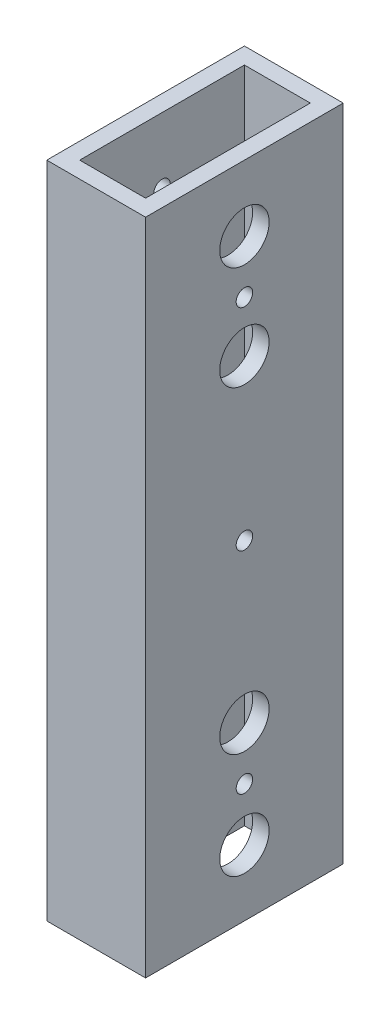
from build123d import *

# Parameters (mm, degrees)
SKETCH1_W           = 19.05
SKETCH1_H           = 38.1
SKETCH1_W_2         = 12.7
SKETCH1_H_2         = 31.75
BOSS_EXTRUDE1_DEPTH = 127
SKETCH2_R           = 1.5875
CUT_EXTRUDE1_DEPTH  = 20.05
CUT_EXTRUDE2_REACH  = 21.05
SKETCH3_R           = 4.7625
SKETCH4_R           = 1.5875
CUT_EXTRUDE3_DEPTH  = 20.05
CUT_EXTRUDE4_REACH  = 21.05
SKETCH5_R           = 4.7625


with BuildPart() as part:
    # Sketch1 → Boss-Extrude1 (new body)
    with BuildSketch(Plane(origin=(0, 0, 0), x_dir=(1, 0, 0), z_dir=(0, 1, 0))):
        with Locations((9.525, 19.05)):
            Rectangle(SKETCH1_W, SKETCH1_H)
        with Locations((9.525, 19.05)):
            Rectangle(SKETCH1_W_2, SKETCH1_H_2, mode=Mode.SUBTRACT)
    extrude(amount=BOSS_EXTRUDE1_DEPTH)

    # Sketch2 → Cut-Extrude1 (cut, through all)
    with BuildSketch(Plane(origin=(19.05, 0, 0), x_dir=(0, 0, -1), z_dir=(1, 0, 0))):
        with Locations((19.05, 12.7)):
            Circle(SKETCH2_R)
        with Locations((19.05, 32.69996)):
            Circle(SKETCH2_R)
        with Locations((19.05, 94.30004)):
            Circle(SKETCH2_R)
        with Locations((19.05, 114.3)):
            Circle(SKETCH2_R)
    extrude(amount=-CUT_EXTRUDE1_DEPTH, mode=Mode.SUBTRACT)

    # Sketch3 → Cut-Extrude2 (cut, up to next)
    with BuildSketch(Plane(origin=(19.05, 0, 0), x_dir=(0, 0, -1), z_dir=(1, 0, 0)), mode=Mode.PRIVATE) as cut_extrude2_sk1:
        with Locations((19.05, 114.3)):
            Circle(SKETCH3_R)
    cut_extrude2_tool1 = extrude(cut_extrude2_sk1.sketch, amount=-CUT_EXTRUDE2_REACH, mode=Mode.PRIVATE) & part.part
    add(cut_extrude2_tool1.solids().sort_by_distance((19.05, 114.3, -19.05))[0], mode=Mode.SUBTRACT)
    # Sketch3 → Cut-Extrude2 (cut, up to next)
    with BuildSketch(Plane(origin=(19.05, 0, 0), x_dir=(0, 0, -1), z_dir=(1, 0, 0)), mode=Mode.PRIVATE) as cut_extrude2_sk2:
        with Locations((19.05, 94.30004)):
            Circle(SKETCH3_R)
    cut_extrude2_tool2 = extrude(cut_extrude2_sk2.sketch, amount=-CUT_EXTRUDE2_REACH, mode=Mode.PRIVATE) & part.part
    add(cut_extrude2_tool2.solids().sort_by_distance((19.05, 94.30004, -19.05))[0], mode=Mode.SUBTRACT)
    # Sketch3 → Cut-Extrude2 (cut, up to next)
    with BuildSketch(Plane(origin=(19.05, 0, 0), x_dir=(0, 0, -1), z_dir=(1, 0, 0)), mode=Mode.PRIVATE) as cut_extrude2_sk3:
        with Locations((19.05, 33.059408242)):
            Circle(SKETCH3_R)
    cut_extrude2_tool3 = extrude(cut_extrude2_sk3.sketch, amount=-CUT_EXTRUDE2_REACH, mode=Mode.PRIVATE) & part.part
    add(cut_extrude2_tool3.solids().sort_by_distance((19.05, 33.059408, -19.05))[0], mode=Mode.SUBTRACT)
    # Sketch3 → Cut-Extrude2 (cut, up to next)
    with BuildSketch(Plane(origin=(19.05, 0, 0), x_dir=(0, 0, -1), z_dir=(1, 0, 0)), mode=Mode.PRIVATE) as cut_extrude2_sk4:
        with Locations((19.05, 12.7)):
            Circle(SKETCH3_R)
    cut_extrude2_tool4 = extrude(cut_extrude2_sk4.sketch, amount=-CUT_EXTRUDE2_REACH, mode=Mode.PRIVATE) & part.part
    add(cut_extrude2_tool4.solids().sort_by_distance((19.05, 12.7, -19.05))[0], mode=Mode.SUBTRACT)

    # Sketch4 → Cut-Extrude3 (cut, through all)
    with BuildSketch(Plane(origin=(19.05, 0, 0), x_dir=(0, 0, -1), z_dir=(1, 0, 0))):
        with Locations((19.05, 22.879704121)):
            Circle(SKETCH4_R)
        with Locations((19.05, 63.5)):
            Circle(SKETCH4_R)
        with Locations((19.05, 104.120295879)):
            Circle(SKETCH4_R)
    extrude(amount=-CUT_EXTRUDE3_DEPTH, mode=Mode.SUBTRACT)

    # Sketch5 → Cut-Extrude4 (cut, up to next)
    with BuildSketch(Plane.ZY, mode=Mode.PRIVATE) as cut_extrude4_sk1:
        with Locations((-19.05, 104.120295879)):
            Circle(SKETCH5_R)
    cut_extrude4_tool1 = extrude(cut_extrude4_sk1.sketch, amount=-CUT_EXTRUDE4_REACH, mode=Mode.PRIVATE) & part.part
    add(cut_extrude4_tool1.solids().sort_by_distance((0, 104.120296, -19.05))[0], mode=Mode.SUBTRACT)
    # Sketch5 → Cut-Extrude4 (cut, up to next)
    with BuildSketch(Plane.ZY, mode=Mode.PRIVATE) as cut_extrude4_sk2:
        with Locations((-19.05, 63.5)):
            Circle(SKETCH5_R)
    cut_extrude4_tool2 = extrude(cut_extrude4_sk2.sketch, amount=-CUT_EXTRUDE4_REACH, mode=Mode.PRIVATE) & part.part
    add(cut_extrude4_tool2.solids().sort_by_distance((0, 63.5, -19.05))[0], mode=Mode.SUBTRACT)
    # Sketch5 → Cut-Extrude4 (cut, up to next)
    with BuildSketch(Plane.ZY, mode=Mode.PRIVATE) as cut_extrude4_sk3:
        with Locations((-19.05, 22.879704121)):
            Circle(SKETCH5_R)
    cut_extrude4_tool3 = extrude(cut_extrude4_sk3.sketch, amount=-CUT_EXTRUDE4_REACH, mode=Mode.PRIVATE) & part.part
    add(cut_extrude4_tool3.solids().sort_by_distance((0, 22.879704, -19.05))[0], mode=Mode.SUBTRACT)


solid = part.part
